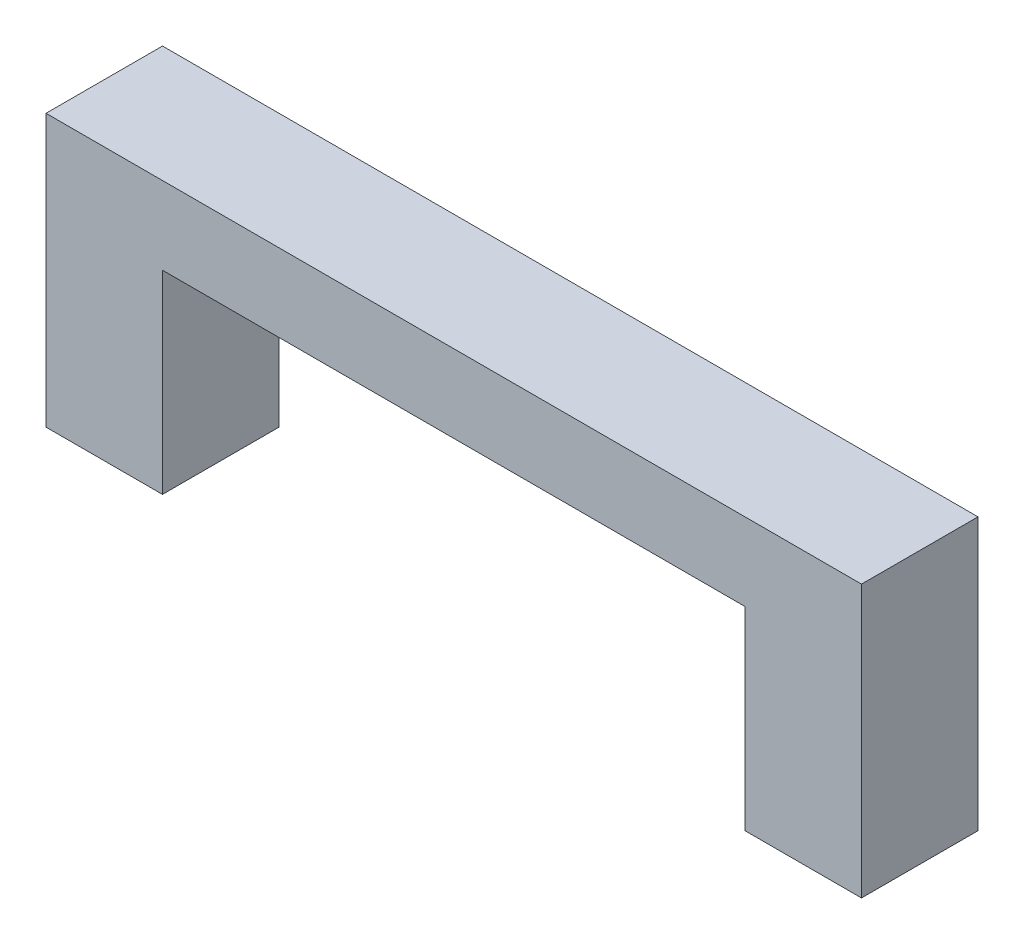
from build123d import *

# Parameters (mm, degrees)
BOSS_EXTRUDE1_DEPTH = 3
SKETCH2_W           = 2
SKETCH2_H           = 2
CUT_EXTRUDE1_DEPTH  = 2.2


with BuildPart() as part:
    # Sketch1 → Boss-Extrude1 (new body)
    with BuildSketch(Plane.XY):
        Polygon((0, 0), (0, 7), (21, 7), (21, 0), (18, 0), (18, 5), (3, 5), (3, 0), align=None)
    extrude(amount=BOSS_EXTRUDE1_DEPTH)

    # Sketch2 → Cut-Extrude1 (cut)
    with BuildSketch(Plane.XZ):
        with Locations((19.5, 1.5)):
            Rectangle(SKETCH2_W, SKETCH2_H)
        with Locations((1.5, 1.5)):
            Rectangle(SKETCH2_W, SKETCH2_H)
    extrude(amount=-CUT_EXTRUDE1_DEPTH, mode=Mode.SUBTRACT)


solid = part.part
